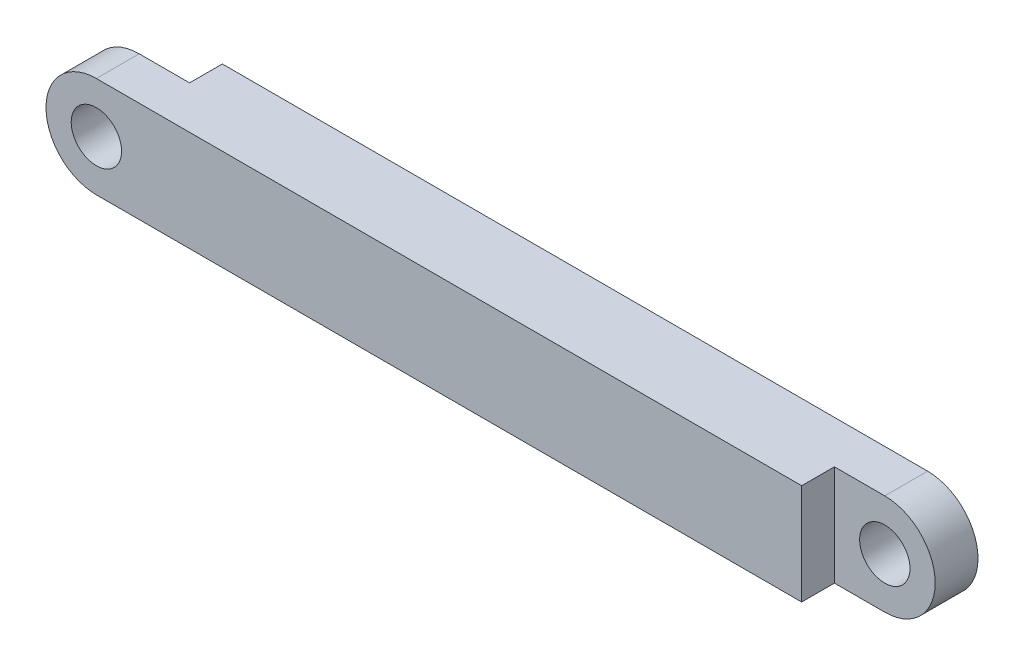
from build123d import *

# Parameters (mm, degrees)
SKETCH_1_R          = 10
EXTRUDE_1_DEPTH     = 15
SKETCH_2_W          = 40
SKETCH_2_H          = 40
CUT_EXTRUDE_2_DEPTH = 13
SKETCH_3_W          = 40
SKETCH_3_H          = 40
CUT_EXTRUDE_3_DEPTH = 13


with BuildPart() as part:
    # Эскиз1 → Бобышка-Вытянуть1 (new body, symmetric)
    with BuildSketch(Plane.XY):
        with BuildLine():
            Line((0, 20), (-300, 20))
            ThreePointArc((-300, 20), (-320, 0), (-300, -20))
            Line((-300, -20), (0, -20))
            ThreePointArc((0, -20), (20, 0), (0, 20))
        make_face()
        with Locations((-300, 0)):
            Circle(SKETCH_1_R, mode=Mode.SUBTRACT)
        Circle(SKETCH_1_R, mode=Mode.SUBTRACT)
    extrude(amount=EXTRUDE_1_DEPTH, both=True)

    # Эскиз2 → Вырез-Вытянуть2 (cut)
    with BuildSketch(Plane.XY.offset(15)):
        Rectangle(SKETCH_2_W, SKETCH_2_H)
    extrude(amount=-CUT_EXTRUDE_2_DEPTH, mode=Mode.SUBTRACT)

    # Эскиз3 → Вырез-Вытянуть3 (cut)
    with BuildSketch(Plane(origin=(0, 0, -15), x_dir=(-1, 0, 0), z_dir=(0, 0, -1))):
        with Locations((300, 0)):
            Rectangle(SKETCH_3_W, SKETCH_3_H)
    extrude(amount=-CUT_EXTRUDE_3_DEPTH, mode=Mode.SUBTRACT)


solid = part.part
